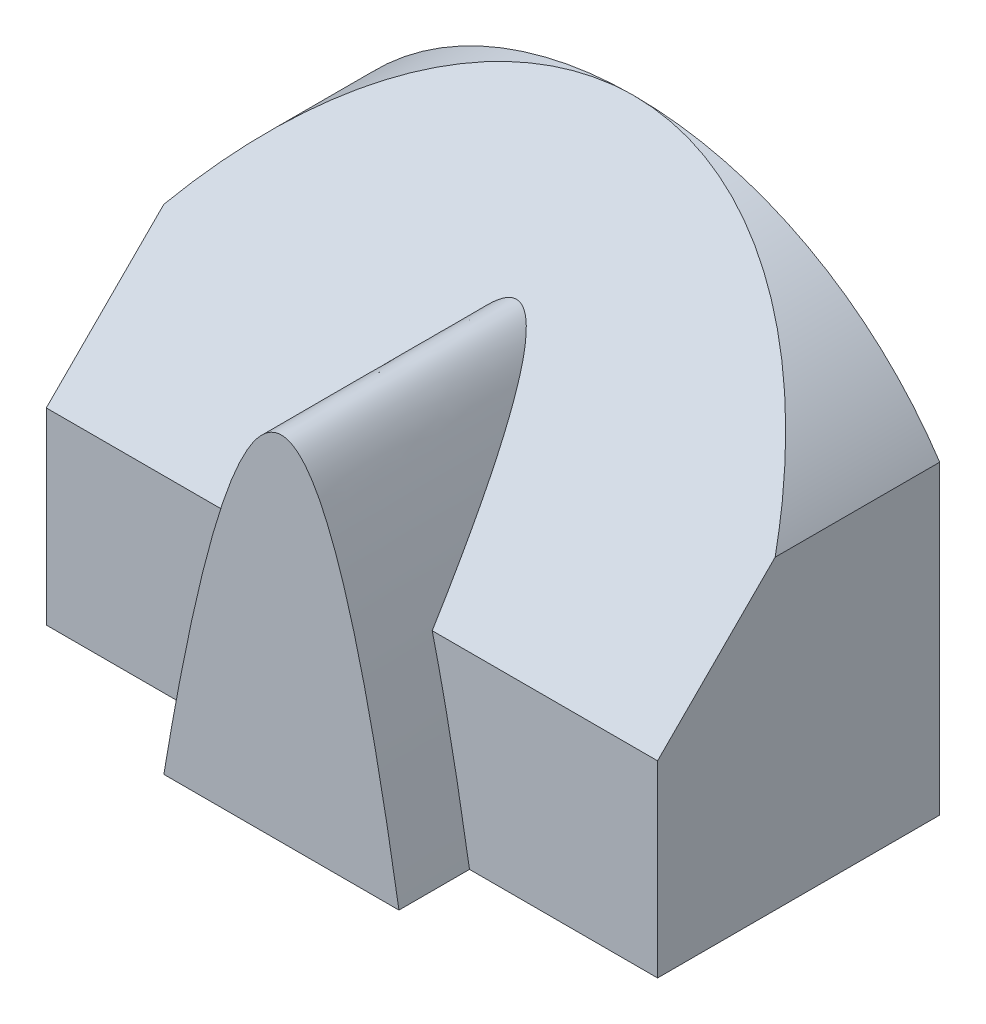
from build123d import *

# Parameters (mm, degrees)
SKETCH1_W           = 130
SKETCH1_H           = 100
EXTRUDE1_DEPTH      = 60
CUT_EXTRUDE1_DEPTH  = 61
CUT_EXTRUDE2_DEPTH  = 131
EXTRUDE2_DEPTH      = 15
EXTRUDE2_DEPTH_BACK = 55


with BuildPart() as part:
    # Sketch1 → Extrude1 (new body)
    with BuildSketch(Plane.XY):
        with Locations((65, 50)):
            Rectangle(SKETCH1_W, SKETCH1_H)
    extrude(amount=-EXTRUDE1_DEPTH)

    # Sketch2 → Cut-Extrude1 (cut, through all)
    with BuildSketch(Plane.XY):
        with BuildLine():
            Line((0, 65), (0, 111.499593367))
            Line((0, 111.499593367), (130, 111.499593367))
            Line((130, 111.499593367), (130, 65))
            ThreePointArc((130, 65), (65, 100), (0, 65))
        make_face()
    extrude(amount=-CUT_EXTRUDE1_DEPTH, mode=Mode.SUBTRACT)

    # Sketch3 → Cut-Extrude2 (cut, through all)
    with BuildSketch(Plane(origin=(130, 0, 0), x_dir=(0, 0, -1), z_dir=(1, 0, 0))):
        Polygon((0, 40), (60, 100), (0, 100), align=None)
    extrude(amount=-CUT_EXTRUDE2_DEPTH, mode=Mode.SUBTRACT)

    # Sketch4 → Extrude2 (add, two sides)
    with BuildSketch(Plane.XY) as extrude2_sk:
        with BuildLine():
            Line((40, 0), (90, 0))
            add(Edge.make_bspline(
                [(40, 0), (65, 150), (90, 0)],
                knots=[0, 0, 0, 1, 1, 1], degree=2))
        make_face()
    extrude(amount=EXTRUDE2_DEPTH)
    extrude(extrude2_sk.sketch, amount=-EXTRUDE2_DEPTH_BACK)


solid = part.part
